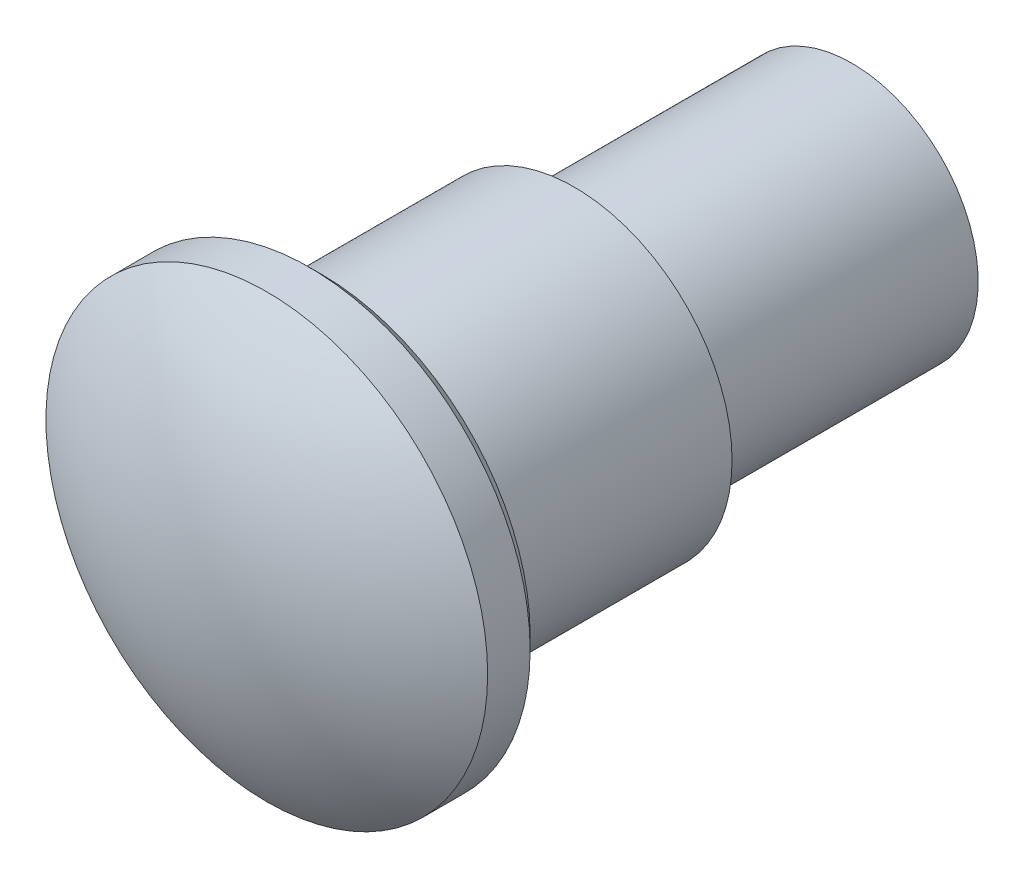
from build123d import *

# Parameters (mm, degrees)
SKETCH2_R           = 1.75
BOSS_EXTRUDE1_DEPTH = 5.2
SKETCH4_OUTSIDE_W   = 6.936
SKETCH4_OUTSIDE_H   = 6.936
SKETCH4_OUTSIDE_R   = 1
CUT_EXTRUDE1_DEPTH  = 2.2
SKETCH5_OUTSIDE_W   = 6.936
SKETCH5_OUTSIDE_H   = 6.936
SKETCH5_OUTSIDE_R   = 1.25
CUT_EXTRUDE2_DEPTH  = 2
CHAMFER1_SIZE       = 0.1


with BuildPart() as part:
    # Sketch2 → Boss-Extrude1 (new body)
    with BuildSketch(Plane.XY):
        Circle(SKETCH2_R)
    extrude(amount=-BOSS_EXTRUDE1_DEPTH)

    # Sketch3 → Cut-Revolve1 (revolve, cut)
    with BuildSketch(Plane(origin=(0, 0, 0), x_dir=(0, 0, -1), z_dir=(1, 0, 0))):
        with BuildLine():
            Line((0, 0), (-0.5, 0))
            Line((-0.5, 0), (-0.5, 1.75))
            Line((-0.5, 1.75), (0.563301414, 1.75))
            ThreePointArc((0.563301414, 1.75), (0.144295555, 0.919212772), (0, 0))
        make_face()
    revolve(axis=Axis((0, 0, 0), (0, 0, -1)), mode=Mode.SUBTRACT)

    # Sketch4 outside → Cut-Extrude1 (cut)
    with BuildSketch(Plane(origin=(0, 0, -5.2), x_dir=(-1, 0, 0), z_dir=(0, 0, -1))):
        Rectangle(SKETCH4_OUTSIDE_W, SKETCH4_OUTSIDE_H)
        Circle(SKETCH4_OUTSIDE_R, mode=Mode.SUBTRACT)
    extrude(amount=-CUT_EXTRUDE1_DEPTH, mode=Mode.SUBTRACT)

    # Sketch5 outside → Cut-Extrude2 (cut)
    with BuildSketch(Plane(origin=(0, 0, -3), x_dir=(-1, 0, 0), z_dir=(0, 0, -1))):
        Rectangle(SKETCH5_OUTSIDE_W, SKETCH5_OUTSIDE_H)
        Circle(SKETCH5_OUTSIDE_R, mode=Mode.SUBTRACT)
    extrude(amount=-CUT_EXTRUDE2_DEPTH, mode=Mode.SUBTRACT)

    # Chamfer1
    chamfer1_edges = [part.edges().sort_by_distance(p)[0] for p in [
        (-1.75, 0, -1),
    ]]
    chamfer(chamfer1_edges, length=CHAMFER1_SIZE)

    # Sketch6 → Cut-Revolve2 (revolve, cut)
    with BuildSketch(Plane(origin=(0, 0, 0), x_dir=(0, 0, -1), z_dir=(1, 0, 0))):
        Polygon((5.2, 0.8), (4.4, 0), (5.2, 0), align=None)
    revolve(axis=Axis((0, 0, 0), (0, 0, -1)), mode=Mode.SUBTRACT)


solid = part.part
